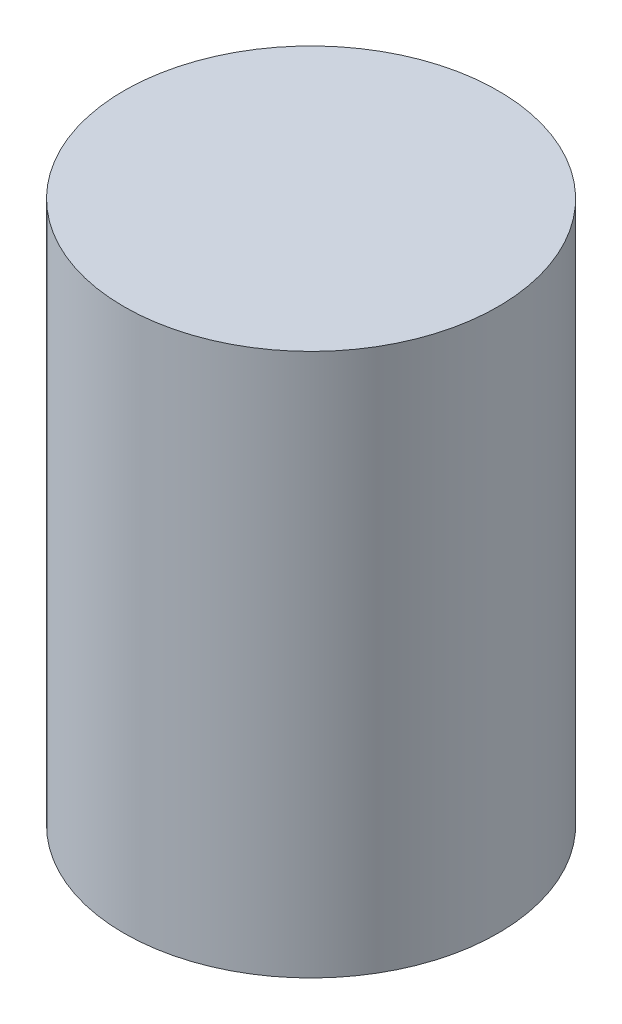
from build123d import *

# Parameters (mm, degrees)
SKETCH1_R           = 31.028783333
BOSS_EXTRUDE1_DEPTH = 90
SKETCH1_5_R         = 26.028783333
CUT_EXTRUDE2_DEPTH  = 85


with BuildPart() as part:
    # Sketch1 → Boss-Extrude1 (new body)
    with BuildSketch(Plane(origin=(0, 0, 0), x_dir=(1, 0, 0), z_dir=(0, 1, 0))):
        Circle(SKETCH1_R)
    extrude(amount=BOSS_EXTRUDE1_DEPTH)

    # Sketch1_5 → Cut-Extrude2 (cut)
    with BuildSketch(Plane(origin=(0, 0, 0), x_dir=(1, 0, 0), z_dir=(0, 1, 0))):
        Circle(SKETCH1_5_R)
    extrude(amount=CUT_EXTRUDE2_DEPTH, mode=Mode.SUBTRACT)


solid = part.part
